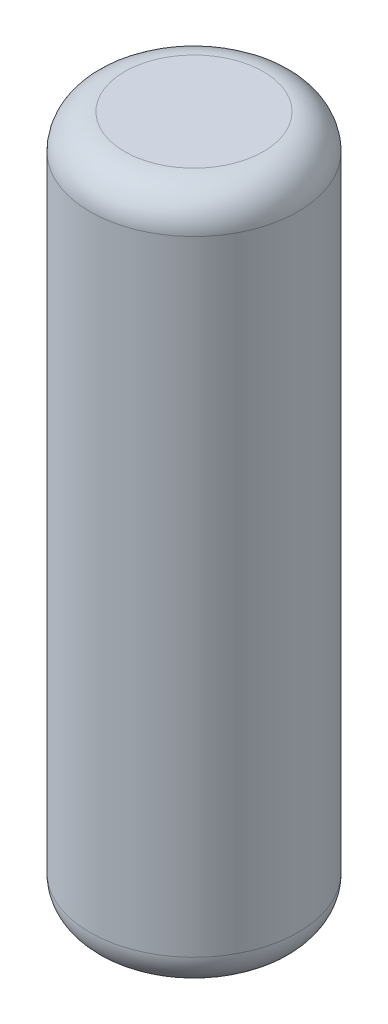
from build123d import *

# Parameters (mm, degrees)
SKETCH1_R           = 30
BOSS_EXTRUDE1_DEPTH = 200
FILLET1_R           = 10


with BuildPart() as part:
    # Sketch1 → Boss-Extrude1 (new body)
    with BuildSketch(Plane(origin=(0, 0, 0), x_dir=(1, 0, 0), z_dir=(0, 1, 0))):
        Circle(SKETCH1_R)
    extrude(amount=BOSS_EXTRUDE1_DEPTH)

    # Fillet1
    fillet1_edges = [part.edges().sort_by_distance(p)[0] for p in [
        (-30, 0, 0),
        (-30, 200, 0),
    ]]
    fillet(fillet1_edges, radius=FILLET1_R)


solid = part.part
